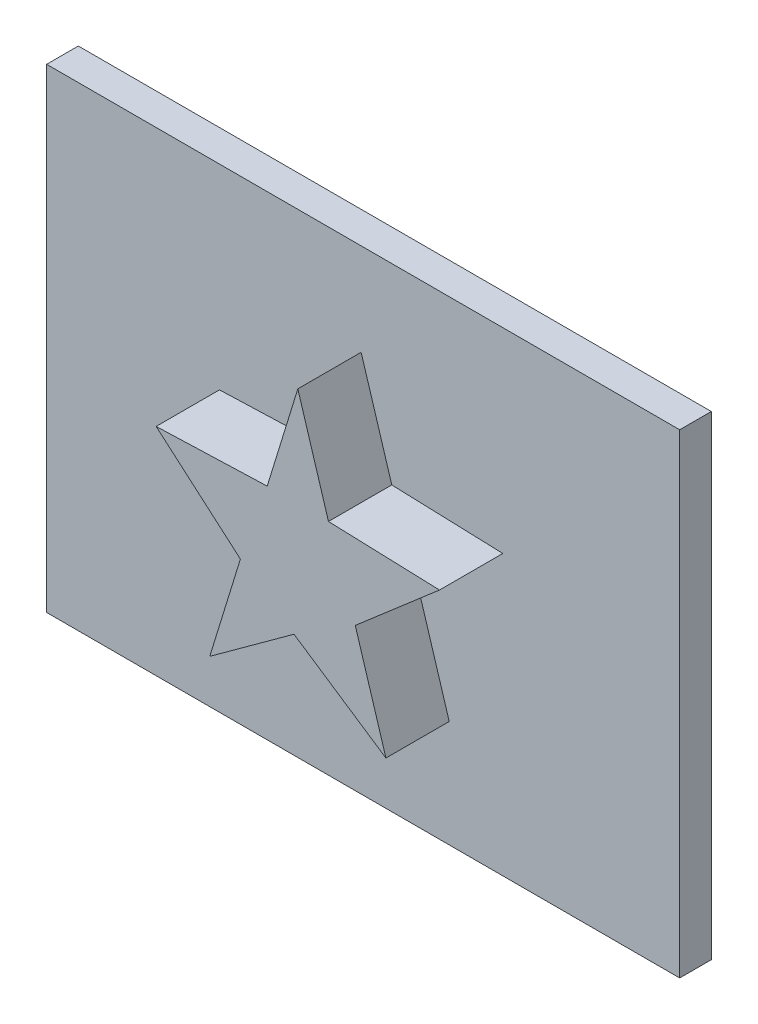
from build123d import *

# Parameters (mm, degrees)
SKETCH1_W           = 40
SKETCH1_H           = 30
BOSS_EXTRUDE1_DEPTH = 2
BOSS_EXTRUDE2_DEPTH = 4


with BuildPart() as part:
    # Sketch1 → Boss-Extrude1 (new body)
    with BuildSketch(Plane.XY):
        Rectangle(SKETCH1_W, SKETCH1_H)
    extrude(amount=BOSS_EXTRUDE1_DEPTH)

    # Sketch2 → Boss-Extrude2 (add)
    with BuildSketch(Plane.XY.offset(2)):
        Polygon((-0.128668655, 9.175508535), (1.807002834, 2.884576195), (8.823811983, 2.642617259), (3.500715387, -1.954602529), (5.436386876, -8.245534869), (-0.370627592, -4.37419189), (-5.693724187, -8.245534869), (-3.758052698, -1.954602529), (-9.081149293, 2.642617259), (-2.064340145, 2.884576195), align=None)
    extrude(amount=BOSS_EXTRUDE2_DEPTH)


solid = part.part
